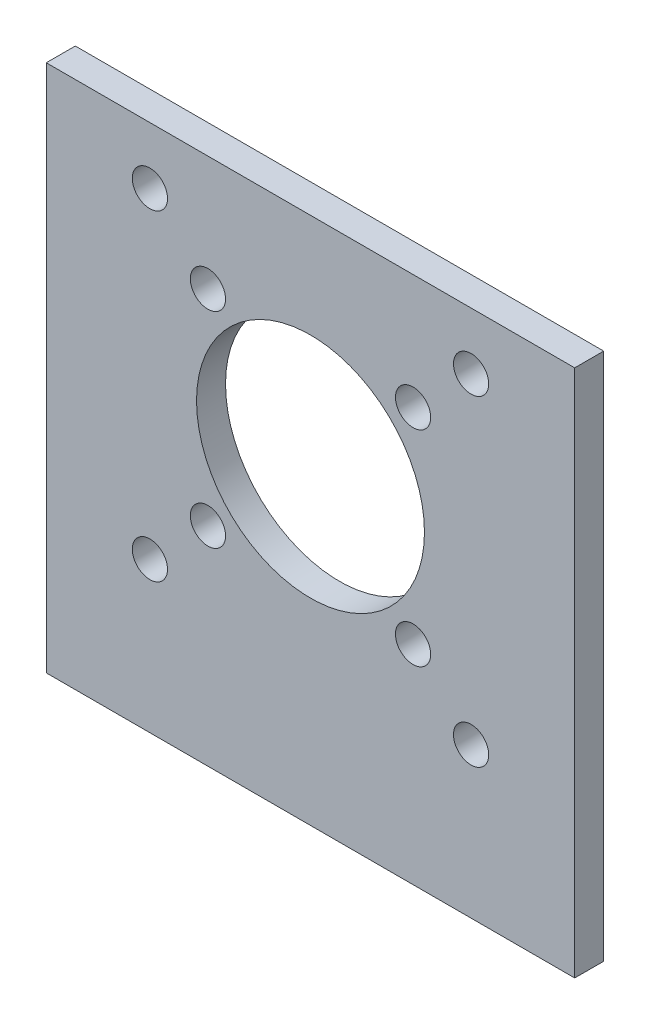
from build123d import *

# Parameters (mm, degrees)
SKETCH1_W           = 51
SKETCH1_H           = 51
BOSS_EXTRUDE1_DEPTH = 2.8
SKETCH2_R           = 11
SKETCH2_R_2         = 1.7
CUT_EXTRUDE1_DEPTH  = 3.8


with BuildPart() as part:
    # Sketch1 → Boss-Extrude1 (new body)
    with BuildSketch(Plane.XY):
        Rectangle(SKETCH1_W, SKETCH1_H)
    extrude(amount=BOSS_EXTRUDE1_DEPTH)

    # Sketch2 → Cut-Extrude1 (cut, through all)
    with BuildSketch(Plane(origin=(0, 0, 0), x_dir=(-1, 0, 0), z_dir=(0, 0, -1))):
        with Locations((0, 4.5)):
            Circle(SKETCH2_R)
        with Locations((-15.5, 20)):
            Circle(SKETCH2_R_2)
        with Locations((15.5, 20)):
            Circle(SKETCH2_R_2)
        with Locations((15.5, -11)):
            Circle(SKETCH2_R_2)
        with Locations((-15.5, -11)):
            Circle(SKETCH2_R_2)
        with Locations((-9.899494937, 14.399494937)):
            Circle(SKETCH2_R_2)
        with Locations((9.899494937, 14.399494937)):
            Circle(SKETCH2_R_2)
        with Locations((9.899494937, -5.399494937)):
            Circle(SKETCH2_R_2)
        with Locations((-9.899494937, -5.399494937)):
            Circle(SKETCH2_R_2)
    extrude(amount=-CUT_EXTRUDE1_DEPTH, mode=Mode.SUBTRACT)


solid = part.part
